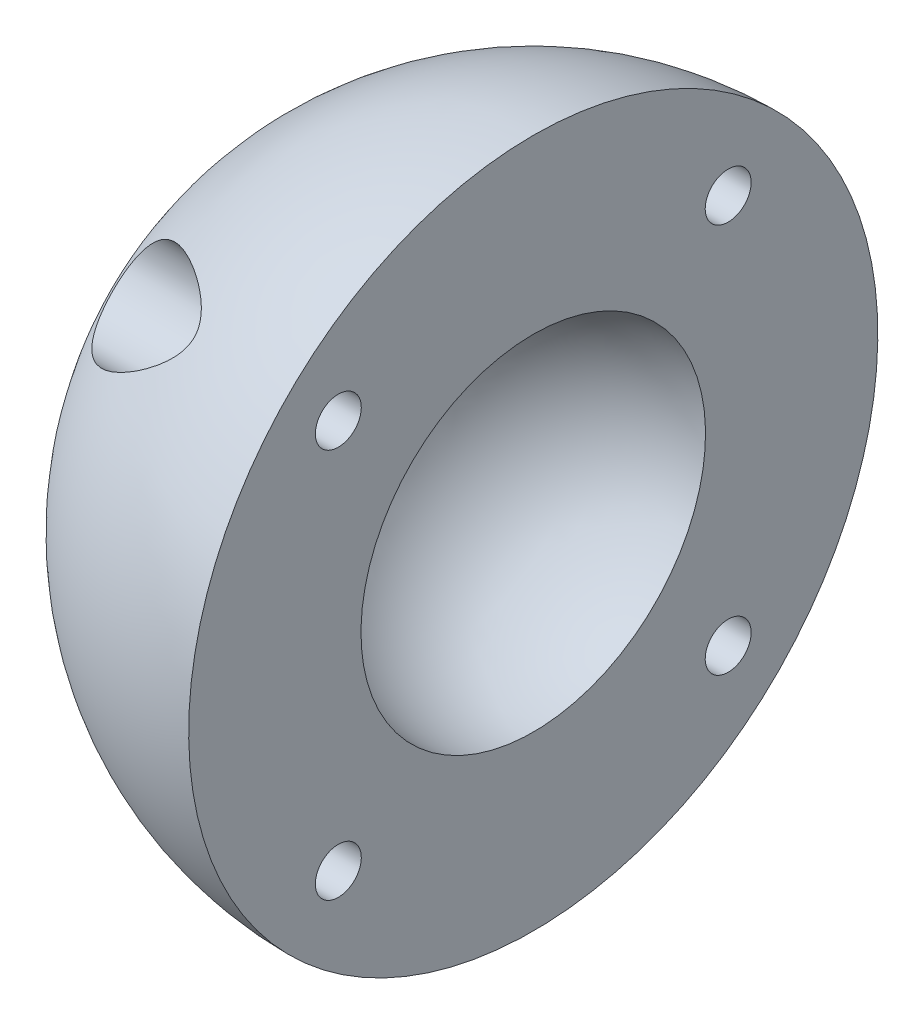
from build123d import *

# Parameters (mm, degrees)
SKETCH4_R               = 2
CUT_EXTRUDE3_DEPTH      = 1
CUT_EXTRUDE3_DEPTH_BACK = 31
SKETCH5_R               = 4.5
CUT_EXTRUDE4_DEPTH      = 28


with BuildPart() as part:
    # Sketch3 → Revolve1 (revolve)
    with BuildSketch(Plane.XY):
        with BuildLine():
            Line((-30, 0), (-15, 0))
            ThreePointArc((-15, 0), (-10.606601718, 10.606601718), (0, 15))
            Line((0, 15), (0, 30))
            ThreePointArc((0, 30), (-21.213203436, 21.213203436), (-30, 0))
        make_face()
    revolve(axis=Axis((0, 0, 0), (-1, 0, 0)))

    # Sketch4 → Cut-Extrude3 (cut, two sides)
    with BuildSketch(Plane(origin=(0, 0, 0), x_dir=(0, 0, -1), z_dir=(1, 0, 0))) as cut_extrude3_sk:
        with Locations((-16.970562748, 16.970562748)):
            Circle(SKETCH4_R)
        with Locations((16.970562748, 16.970562748)):
            Circle(SKETCH4_R)
        with Locations((16.970562748, -16.970562748)):
            Circle(SKETCH4_R)
        with Locations((-16.970562748, -16.970562748)):
            Circle(SKETCH4_R)
    extrude(amount=CUT_EXTRUDE3_DEPTH, mode=Mode.SUBTRACT)
    extrude(cut_extrude3_sk.sketch, amount=-CUT_EXTRUDE3_DEPTH_BACK, mode=Mode.SUBTRACT)

    # Sketch5 → Cut-Extrude4 (cut, through all)
    with BuildSketch(Plane(origin=(-3, 0, 0), x_dir=(0, 0, -1), z_dir=(1, 0, 0))):
        with Locations((-16.970562748, 16.970562748)):
            Circle(SKETCH5_R)
        with Locations((16.970562748, 16.970562748)):
            Circle(SKETCH5_R)
        with Locations((16.970562748, -16.970562748)):
            Circle(SKETCH5_R)
        with Locations((-16.970562748, -16.970562748)):
            Circle(SKETCH5_R)
    extrude(amount=-CUT_EXTRUDE4_DEPTH, mode=Mode.SUBTRACT)


solid = part.part
